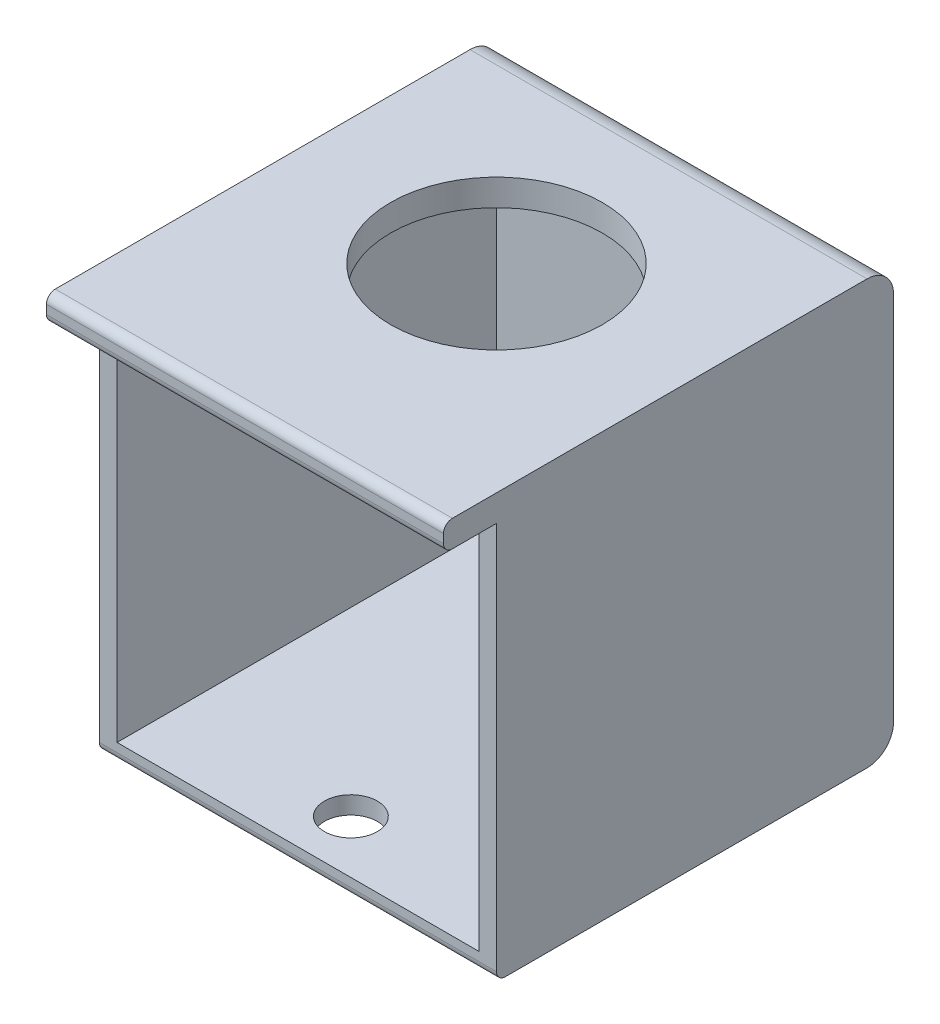
from build123d import *

# Parameters (mm, degrees)
SKETCH_1_W          = 45
SKETCH_1_H          = 45
EXTRUDE_1_DEPTH     = 3
SKETCH_2_R          = 12
CUT_EXTRUDE_1_DEPTH = 3
SKETCH_3_W          = 2
SKETCH_3_H          = 45
EXTRUDE_3_DEPTH     = 45
SKETCH_4_R          = 12
CUT_EXTRUDE_2_DEPTH = 3
SKETCH_5_W          = 41
SKETCH_5_H          = 2
EXTRUDE_4_DEPTH     = 45
SKETCH_6_W          = 41
SKETCH_6_H          = 2
EXTRUDE_5_DEPTH     = 43
SKETCH_8_W          = 45
SKETCH_8_H          = 3
EXTRUDE_6_DEPTH     = 6
FILLET_3_R          = 1
FILLET_4_R          = 3
SKETCH_9_R          = 3
CUT_EXTRUDE_3_DEPTH = 2
FILLET_8_R          = 1


with BuildPart() as part:
    # Эскиз1 → Бобышка-Вытянуть1 (new body)
    with BuildSketch(Plane(origin=(0, 0, 0), x_dir=(1, 0, 0), z_dir=(0, 1, 0))):
        Rectangle(SKETCH_1_W, SKETCH_1_H)
    extrude_1 = extrude(amount=EXTRUDE_1_DEPTH)

    # Эскиз2 → Вырез-Вытянуть1 (cut)
    with BuildSketch(Plane(origin=(0, 3, 0), x_dir=(1, 0, 0), z_dir=(0, 1, 0))):
        Circle(SKETCH_2_R)
    extrude(amount=-CUT_EXTRUDE_1_DEPTH, mode=Mode.SUBTRACT)

    # Эскиз3 → Бобышка-Вытянуть3 (add)
    with BuildSketch(Plane.XZ):
        with Locations((-21.5, 0)):
            Rectangle(SKETCH_3_W, SKETCH_3_H)
    extrude_3 = extrude(amount=EXTRUDE_3_DEPTH)

    # Зеркальное отражение3: Бобышка-Вытянуть1, Бобышка-Вытянуть3 across plane
    add(extrude_1.mirror(Plane.ZY))
    add(extrude_3.mirror(Plane.ZY))

    # Эскиз4 → Вырез-Вытянуть2 (cut)
    with BuildSketch(Plane(origin=(0, 3, 0), x_dir=(1, 0, 0), z_dir=(0, 1, 0))):
        Circle(SKETCH_4_R)
    extrude(amount=-CUT_EXTRUDE_2_DEPTH, mode=Mode.SUBTRACT)

    # Эскиз5 → Бобышка-Вытянуть4 (add)
    with BuildSketch(Plane.XZ):
        with Locations((0, -21.5)):
            Rectangle(SKETCH_5_W, SKETCH_5_H)
    extrude(amount=EXTRUDE_4_DEPTH)

    # Эскиз6 → Бобышка-Вытянуть5 (add)
    with BuildSketch(Plane.XY.offset(-20.5)):
        with Locations((0, -44)):
            Rectangle(SKETCH_6_W, SKETCH_6_H)
    extrude(amount=EXTRUDE_5_DEPTH)

    # Эскиз8 → Бобышка-Вытянуть6 (add)
    with BuildSketch(Plane.XY.offset(22.5)):
        with Locations((0, 1.5)):
            Rectangle(SKETCH_8_W, SKETCH_8_H)
    extrude(amount=EXTRUDE_6_DEPTH)

    # Скругление3
    fillet_3_edges = [part.edges().sort_by_distance(p)[0] for p in [
        (0, 0, 28.5),
        (0, 3, 28.5),
    ]]
    fillet(fillet_3_edges, radius=FILLET_3_R)

    # Скругление4
    fillet_4_edges = [part.edges().sort_by_distance(p)[0] for p in [
        (0, -45, -22.5),
        (0, 3, -22.5),
    ]]
    fillet(fillet_4_edges, radius=FILLET_4_R)

    # Эскиз9 → Вырез-Вытянуть3 (cut)
    with BuildSketch(Plane.XZ.offset(45)):
        with Locations((0, 16.5)):
            Circle(SKETCH_9_R)
    extrude(amount=-CUT_EXTRUDE_3_DEPTH, mode=Mode.SUBTRACT)

    # Скругление8
    fillet_8_edges = [part.edges().sort_by_distance(p)[0] for p in [
        (0, -45, 22.5),
    ]]
    fillet(fillet_8_edges, radius=FILLET_8_R)


solid = part.part
